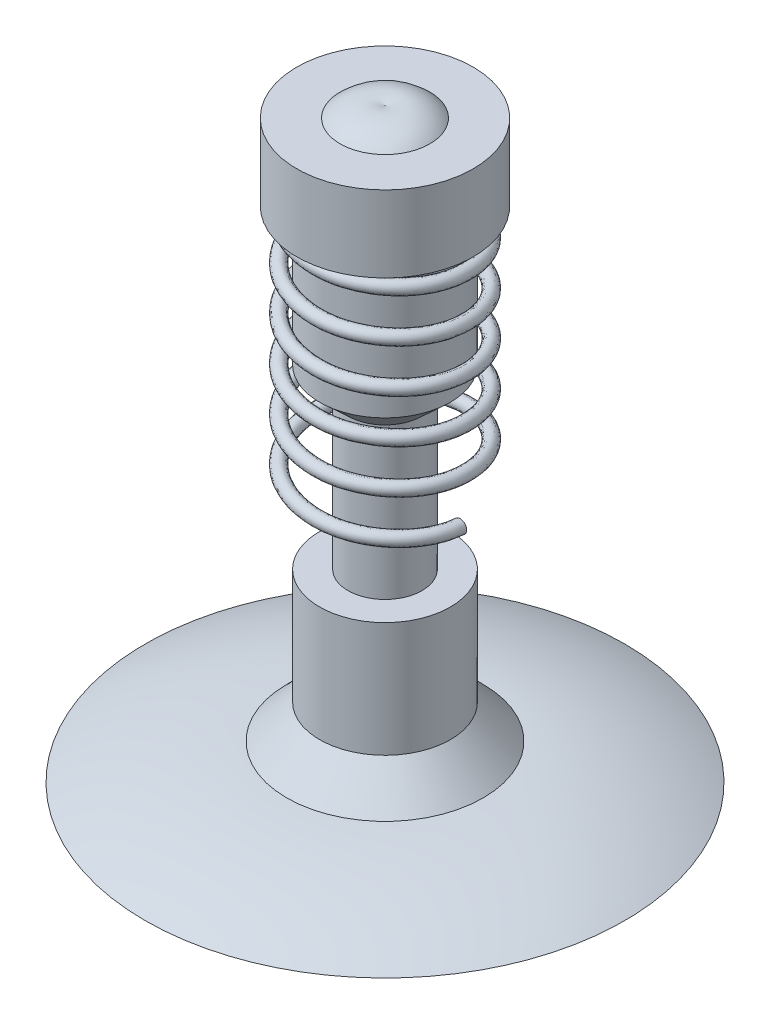
from build123d import *

# Parameters (mm, degrees)
SWEEP1_PITCH       = 0.2
SWEEP1_HEIGHT      = 1.1
SWEEP1_RADIUS      = 0.345
SWEEP1_START_ANGLE = -90
SKETCH4_R          = 0.03


with BuildPart() as part:
    # Sketch2 → Revolve1 (revolve)
    with BuildSketch(Plane.XY):
        with BuildLine():
            Line((0, 0), (0, 2.69))
            ThreePointArc((0, 2.69), (0.110151103, 2.694549778), (0.205954483, 2.64))
            Line((0.205954483, 2.64), (0.40470766, 2.64))
            Line((0.40470766, 2.64), (0.40470766, 2.29))
            Line((0.40470766, 2.29), (0.3, 2.29))
            Line((0.3, 2.29), (0.3, 1.66))
            Line((0.3, 1.66), (0.17, 1.540046316))
            Line((0.17, 1.540046316), (0.17, 0.846574221))
            Line((0.17, 0.846574221), (0.3, 0.846574221))
            Line((0.3, 0.846574221), (0.3, 0.31927945))
            Line((0.3, 0.31927945), (0.450926, 0.163391695))
            ThreePointArc((0.450926, 0.163391695), (0.784357148, 0.117027877), (1.1, 0))
            Line((1.1, 0), (0, 0))
        make_face()
    revolve(axis=Axis((0, 0, 0), (0, 1, 0)))

    # Sweep1: sweep along a helix
    with BuildLine() as sweep1_path:
        add(Helix(SWEEP1_PITCH, SWEEP1_HEIGHT, SWEEP1_RADIUS, center=(0, 2.29, 0), direction=(0, -1, 0), lefthand=True, mode=Mode.PRIVATE).rotate(Axis((0, 2.29, 0), (0, -1, 0)), SWEEP1_START_ANGLE))
    # Sketch4 → Sweep1 (sweep)
    with BuildSketch(Plane.XY):
        with Locations((0.345, 1.19)):
            Circle(SKETCH4_R)
    sweep(path=sweep1_path.line, is_frenet=True)


solid = part.part
